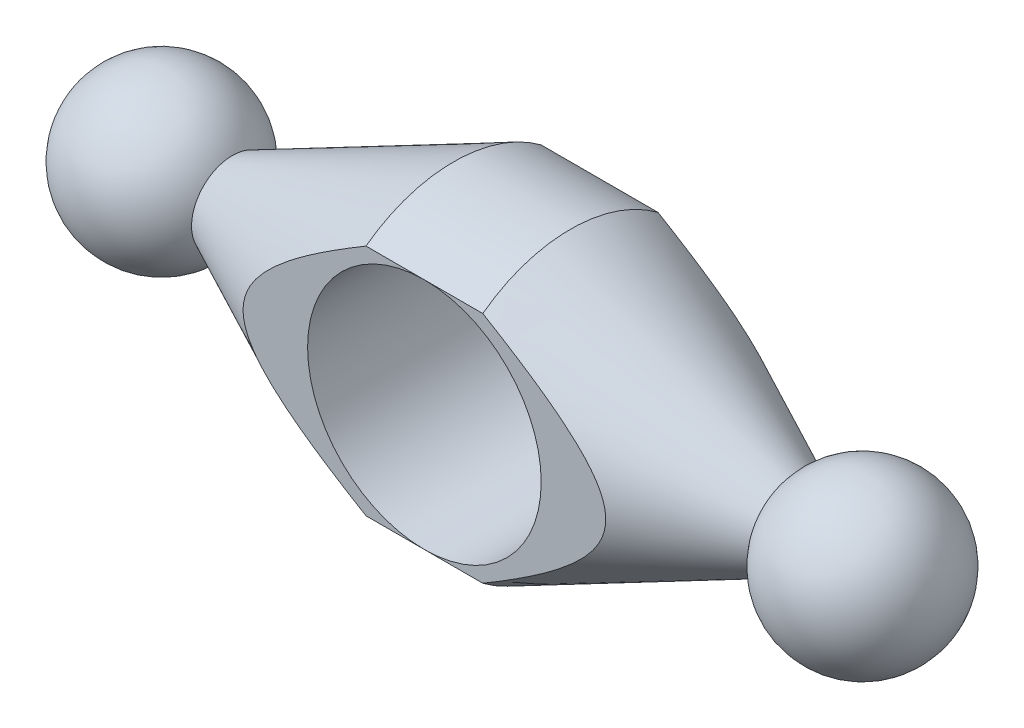
from build123d import *


with BuildPart() as part:
    # Эскиз1 → Повернуть1 (revolve)
    with BuildSketch(Plane.XY):
        with BuildLine():
            Line((13.062177826, 3.5), (32, 12.5))
            Line((32, 12.5), (42, 12.5))
            Line((42, 12.5), (60.937822174, 3.5))
            ThreePointArc((60.937822174, 3.5), (68.811733316, 6.761480784), (74, 0))
            Line((74, 0), (0, 0))
            ThreePointArc((0, 0), (5.188266684, 6.761480784), (13.062177826, 3.5))
        make_face()
    revolve(axis=Axis((0, 0, 0), (1, 0, 0)))

    # Эскиз4 → Вырез-Повернуть1 (revolve, cut)
    with BuildSketch(Plane(origin=(37, 0, 0), x_dir=(0, 0, -1), z_dir=(1, 0, 0))):
        Polygon((-7.5, 10), (7.5, 10), (7.5, 20), (15, 20), (15, 0), (-15, 0), (-15, 20), (-7.5, 20), align=None)
    revolve(axis=Axis((37, 0, 0), (0, 0, -1)), mode=Mode.SUBTRACT)


solid = part.part
